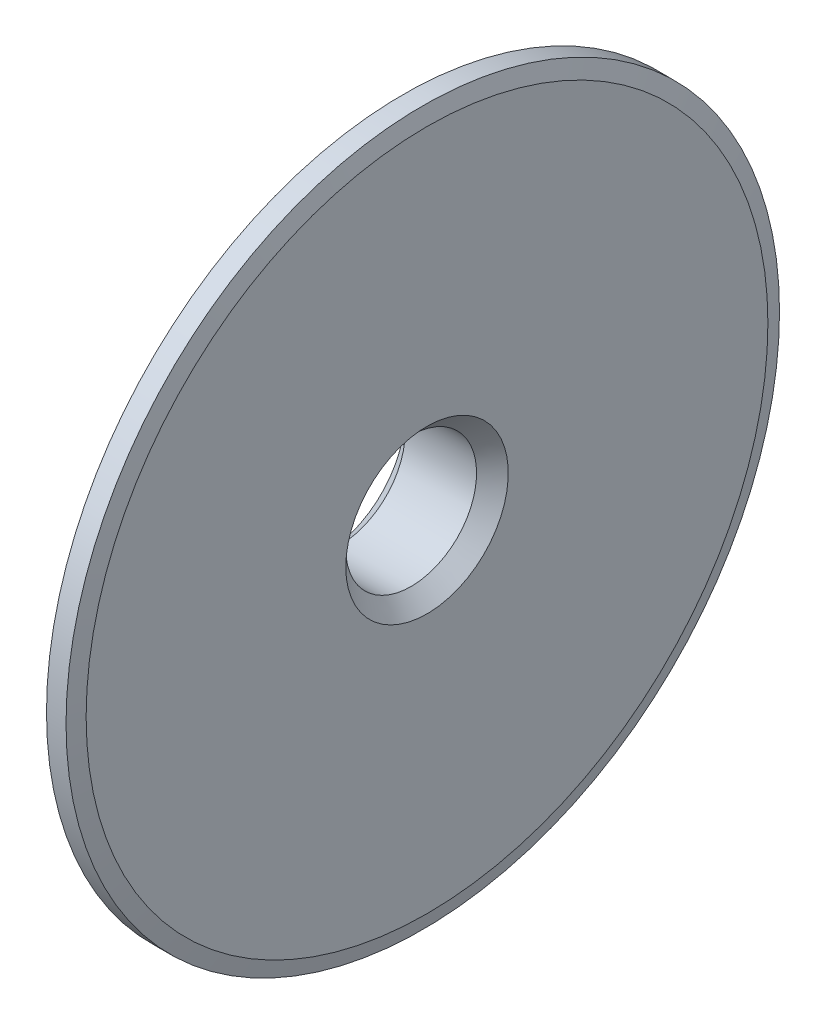
from build123d import *

# Parameters (mm, degrees)
CHAMFER_1_SIZE = 2
CHAMFER_3_SIZE = 0.5


with BuildPart() as part:
    # Эскиз1 → Повернуть1 (revolve)
    with BuildSketch(Plane.XY):
        Polygon((0, 8.25), (13, 8.25), (13, 43), (12.464101615, 45), (10, 45), (10, 32.5), (4, 32.5), (4, 30.5), (10, 30.5), (10, 12.5), (0, 12.5), align=None)
    revolve(axis=Axis((0, 0, 0), (1, 0, 0)))

    # Фаска1
    chamfer_1_edges = [part.edges().sort_by_distance(p)[0] for p in [
        (13, -8.25, 0),
        (0, -8.25, 0),
    ]]
    chamfer(chamfer_1_edges, length=CHAMFER_1_SIZE)

    # Фаска3
    chamfer_3_edges = [part.edges().sort_by_distance(p)[0] for p in [
        (4, -30.5, 0),
        (4, -32.5, 0),
        (0, -12.5, 0),
    ]]
    chamfer(chamfer_3_edges, length=CHAMFER_3_SIZE)


solid = part.part
